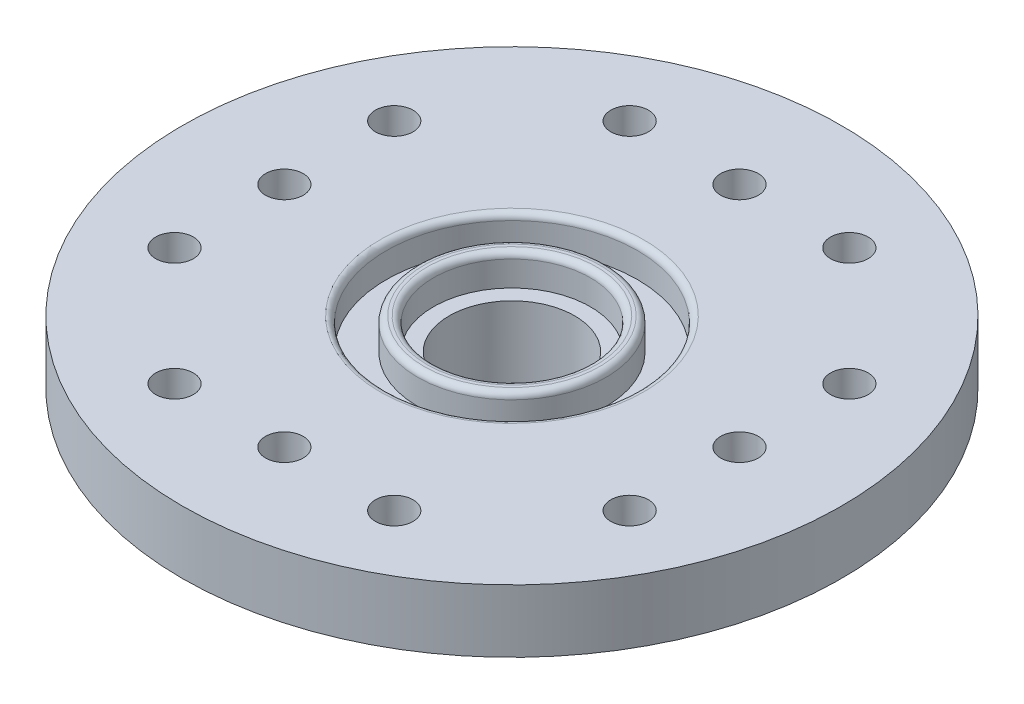
from build123d import *

# Parameters (mm, degrees)
CROQUIS1_R              = 10.5
SALIENTE_EXTRUIR1_DEPTH = 2
CROQUIS2_R              = 4
CROQUIS2_R_2            = 2
SALIENTE_EXTRUIR2_DEPTH = 3
REDONDEO1_R             = 1
CROQUIS3_R              = 4
CROQUIS3_R_2            = 3
CORTAR_EXTRUIR1_DEPTH   = 1
CROQUIS4_R              = 2
CORTAR_EXTRUIR2_DEPTH   = 3
CROQUIS5_R              = 2.5
CORTAR_EXTRUIR3_DEPTH   = 1
CROQUIS6_R              = 0.6
CORTAR_EXTRUIR4_DEPTH   = 6
MATRIZC1_COUNT          = 4
REDONDEO2_R             = 0.2


with BuildPart() as part:
    # Croquis1 → Saliente-Extruir1 (new body)
    with BuildSketch(Plane(origin=(0, 0, 0), x_dir=(1, 0, 0), z_dir=(0, 1, 0))):
        Circle(CROQUIS1_R)
    extrude(amount=SALIENTE_EXTRUIR1_DEPTH)

    # Croquis2 → Saliente-Extruir2 (add)
    with BuildSketch(Plane.XZ):
        Circle(CROQUIS2_R)
        Circle(CROQUIS2_R_2, mode=Mode.SUBTRACT)
    extrude(amount=SALIENTE_EXTRUIR2_DEPTH)

    # Redondeo1
    redondeo1_edges = [part.edges().sort_by_distance(p)[0] for p in [
        (-4, -3, 0),
    ]]
    fillet(redondeo1_edges, radius=REDONDEO1_R)

    # Croquis3 → Cortar-Extruir1 (cut)
    with BuildSketch(Plane(origin=(0, 2, 0), x_dir=(1, 0, 0), z_dir=(0, 1, 0))):
        Circle(CROQUIS3_R)
        Circle(CROQUIS3_R_2, mode=Mode.SUBTRACT)
    extrude(amount=-CORTAR_EXTRUIR1_DEPTH, mode=Mode.SUBTRACT)

    # Croquis4 → Cortar-Extruir2 (cut)
    with BuildSketch(Plane(origin=(0, 2, 0), x_dir=(1, 0, 0), z_dir=(0, 1, 0))):
        Circle(CROQUIS4_R)
    extrude(amount=-CORTAR_EXTRUIR2_DEPTH, mode=Mode.SUBTRACT)

    # Croquis5 → Cortar-Extruir3 (cut)
    with BuildSketch(Plane(origin=(0, 2, 0), x_dir=(1, 0, 0), z_dir=(0, 1, 0))):
        Circle(CROQUIS5_R)
    extrude(amount=-CORTAR_EXTRUIR3_DEPTH, mode=Mode.SUBTRACT)

    # Croquis6 → Cortar-Extruir4 (cut, through all)
    with BuildSketch(Plane(origin=(0, 2, 0), x_dir=(1, 0, 0), z_dir=(0, 1, 0))):
        with Locations((0, 7.25)):
            Circle(CROQUIS6_R)
        with Locations((3.5, 7.25)):
            Circle(CROQUIS6_R)
        with Locations((-3.5, 7.25)):
            Circle(CROQUIS6_R)
    cortar_extruir4 = extrude(amount=-CORTAR_EXTRUIR4_DEPTH, mode=Mode.SUBTRACT)

    # MatrizC1: Cortar-Extruir4 ×4 about axis
    matrizc1_axis = Axis((0, 0, 0), (0, 1, 0))
    for i in range(1, MATRIZC1_COUNT):
        add(cortar_extruir4.rotate(matrizc1_axis, i * 360 / MATRIZC1_COUNT), mode=Mode.SUBTRACT)

    # Redondeo2
    redondeo2_edges = [part.edges().sort_by_distance(p)[0] for p in [
        (-4, 2, 0),
        (-3, 2, 0),
        (-2.5, 2, 0),
    ]]
    fillet(redondeo2_edges, radius=REDONDEO2_R)


solid = part.part
